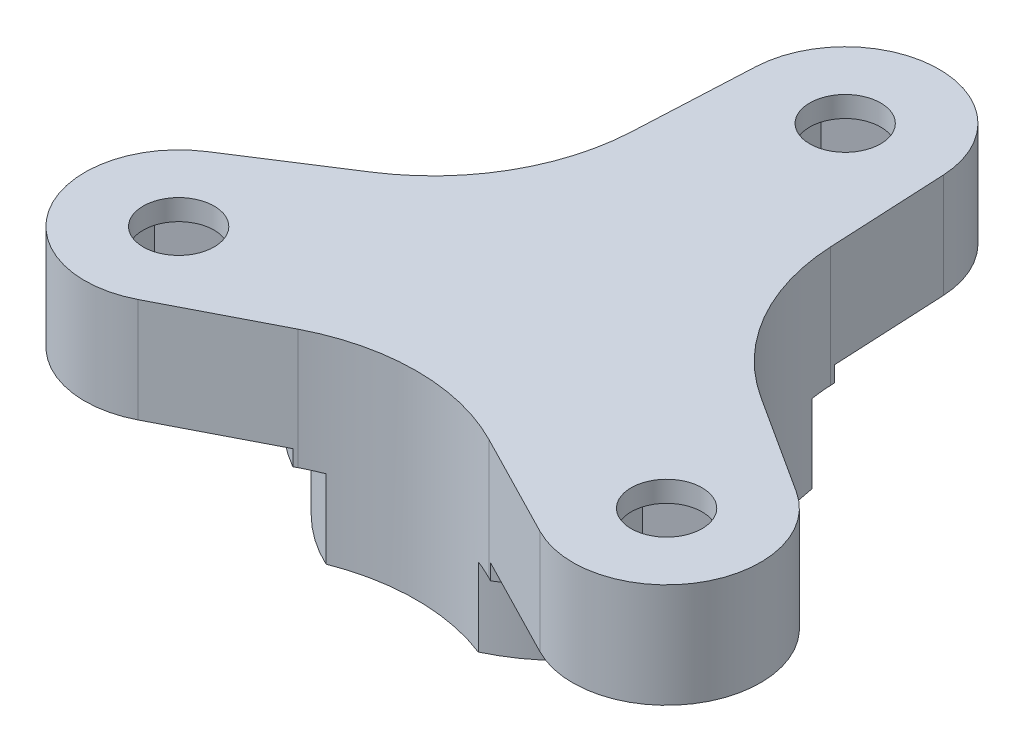
from build123d import *

# Parameters (mm, degrees)
SKETCH1_R           = 1.7
BOSS_EXTRUDE1_DEPTH = 5
CUT_EXTRUDE1_START  = -5
CUT_EXTRUDE1_DEPTH  = 4
BOSS_EXTRUDE3_DEPTH = 4.5
BOSS_EXTRUDE4_DEPTH = 0.75


with BuildPart() as part:
    # Sketch1 → Boss-Extrude1 (new body)
    with BuildSketch(Plane(origin=(0, 0, 0), x_dir=(1, 0, 0), z_dir=(0, 1, 0))):
        with BuildLine():
            Line((-4.494644994, 13.719468408), (-4.772250922, 8.034184997))
            ThreePointArc((-4.772250922, 8.034184997), (-6.10009687, 3.52189257), (-9.343933767, 0.115798034))
            Line((-9.343933767, 0.115798034), (-14.128730664, -2.967257459))
            ThreePointArc((-14.128730664, -2.967257459), (-15.588457268, -9), (-9.634085671, -10.752210949))
            Line((-9.634085671, -10.752210949), (-4.571682845, -8.149983031))
            ThreePointArc((-4.571682845, -8.149983031), (0, -7.04378514), (4.571682845, -8.149983031))
            Line((4.571682845, -8.149983031), (9.634085671, -10.752210949))
            ThreePointArc((9.634085671, -10.752210949), (15.588457268, -9), (14.128730664, -2.967257459))
            Line((14.128730664, -2.967257459), (9.343933767, 0.115798034))
            ThreePointArc((9.343933767, 0.115798034), (6.10009687, 3.52189257), (4.772250922, 8.034184997))
            Line((4.772250922, 8.034184997), (4.494644994, 13.719468408))
            ThreePointArc((4.494644994, 13.719468408), (0, 18), (-4.494644994, 13.719468408))
        make_face()
        with Locations((0, 13.5)):
            Circle(SKETCH1_R, mode=Mode.SUBTRACT)
        with Locations((11.691342951, -6.75)):
            Circle(SKETCH1_R, mode=Mode.SUBTRACT)
        with Locations((-11.691342951, -6.75)):
            Circle(SKETCH1_R, mode=Mode.SUBTRACT)
    extrude(amount=BOSS_EXTRUDE1_DEPTH)

    # Sketch2 → Cut-Extrude1 (cut)
    with BuildSketch(Plane(origin=(0, 5, 0), x_dir=(1, 0, 0), z_dir=(0, 1, 0)).offset(CUT_EXTRUDE1_START)):
        Polygon((14.441342951, -8.33771324), (14.441342951, -5.16228676), (11.691342951, -3.574573519), (8.941342951, -5.16228676), (8.941342951, -8.33771324), (11.691342951, -9.925426481), align=None)
        Polygon((0, 16.675426481), (-2.75, 15.08771324), (-2.75, 11.91228676), (0, 10.324573519), (2.75, 11.91228676), (2.75, 15.08771324), align=None)
        Polygon((-14.441342951, -8.33771324), (-11.691342951, -9.925426481), (-8.941342951, -8.33771324), (-8.941342951, -5.16228676), (-11.691342951, -3.574573519), (-14.441342951, -5.16228676), align=None)
    extrude(amount=CUT_EXTRUDE1_DEPTH, mode=Mode.SUBTRACT)

    # Sketch7 → Boss-Extrude3 (add)
    with BuildSketch(Plane.XZ):
        with BuildLine():
            ThreePointArc((-4.872953171, -7.025441438), (0, -8.55), (4.872953171, -7.025441438))
            ThreePointArc((4.872953171, -7.025441438), (6.10009687, -3.52189257), (8.520687343, -0.707380519))
            ThreePointArc((8.520687343, -0.707380519), (7.404517202, 4.275), (3.647734172, 7.732821956))
            ThreePointArc((3.647734172, 7.732821956), (0, 7.04378514), (-3.647734172, 7.732821956))
            ThreePointArc((-3.647734172, 7.732821956), (-7.404517202, 4.275), (-8.520687343, -0.707380519))
            ThreePointArc((-8.520687343, -0.707380519), (-6.10009687, -3.52189257), (-4.872953171, -7.025441438))
        make_face()
    extrude(amount=BOSS_EXTRUDE3_DEPTH)

    # Sketch8 → Boss-Extrude4 (add)
    with BuildSketch(Plane.XZ):
        with BuildLine():
            Line((-9.343933767, -0.115798034), (-9.499987767, -0.015245565))
            ThreePointArc((-9.499987767, -0.015245565), (-8.227241336, 4.75), (-4.736790837, 8.234853524))
            Line((-4.736790837, 8.234853524), (-4.571682845, 8.149983031))
            ThreePointArc((-4.571682845, 8.149983031), (-4.114998161, 7.929686713), (-3.647734172, 7.732821956))
            ThreePointArc((-3.647734172, 7.732821956), (-7.404517202, 4.275), (-8.520687343, -0.707380519))
            ThreePointArc((-8.520687343, -0.707380519), (-8.924809218, -0.401150413), (-9.343933767, -0.115798034))
        make_face()
        with BuildLine():
            Line((4.571682845, 8.149983031), (4.736790837, 8.234853524))
            ThreePointArc((4.736790837, 8.234853524), (8.227241336, 4.75), (9.499987767, -0.015245565))
            Line((9.499987767, -0.015245565), (9.343933767, -0.115798034))
            ThreePointArc((9.343933767, -0.115798034), (8.924809218, -0.401150413), (8.520687343, -0.707380519))
            ThreePointArc((8.520687343, -0.707380519), (7.404517202, 4.275), (3.647734172, 7.732821956))
            ThreePointArc((3.647734172, 7.732821956), (4.114998161, 7.929686713), (4.571682845, 8.149983031))
        make_face()
        with BuildLine():
            Line((4.772250922, -8.034184997), (4.76319693, -8.219607959))
            ThreePointArc((4.76319693, -8.219607959), (0, -9.5), (-4.76319693, -8.219607959))
            Line((-4.76319693, -8.219607959), (-4.772250922, -8.034184997))
            ThreePointArc((-4.772250922, -8.034184997), (-4.809811057, -7.528536301), (-4.872953171, -7.025441437))
            ThreePointArc((-4.872953171, -7.025441437), (0, -8.55), (4.872953171, -7.025441438))
            ThreePointArc((4.872953171, -7.025441438), (4.809811057, -7.528536301), (4.772250922, -8.034184997))
        make_face()
    extrude(amount=BOSS_EXTRUDE4_DEPTH)


solid = part.part
